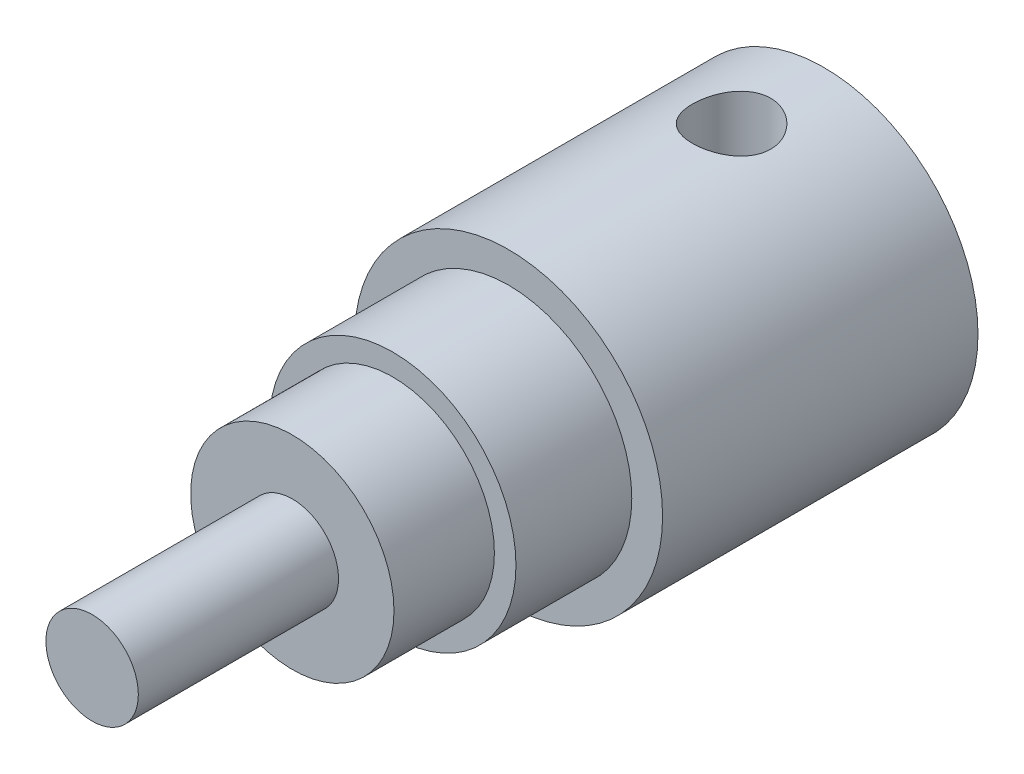
from build123d import *

# Parameters (mm, degrees)
ESQUISSE1_R                  = 25
BOSS_EXTRU_1_DEPTH           = 51.2
ESQUISSE2_R                  = 20
BOSS_EXTRU_2_DEPTH           = 18.8
ESQUISSE3_R                  = 16.5
BOSS_EXTRU_3_DEPTH           = 16.7
ESQUISSE4_R                  = 27.5
BOSS_EXTRU_4_DEPTH           = 47.1
CHANFREIN1_SIZE              = 10
CHANFREIN1_SIZE2             = 17.320508076
ESQUISSE12_R                 = 6.35
ENL_V_MAT_EXTRU_1_DEPTH      = 28.5
ENL_V_MAT_EXTRU_1_DEPTH_BACK = 28.5
ESQUISSE13_R                 = 47.258439022
ENL_V_MAT_EXTRU_2_DEPTH      = 15
ESQUISSE14_R                 = 39.934727028
ESQUISSE14_R_2               = 7.5
ENL_V_MAT_EXTRU_4_DEPTH      = 32.5


with BuildPart() as part:
    # Esquisse1 → Boss.-Extru.1 (new body)
    with BuildSketch(Plane.XY):
        Circle(ESQUISSE1_R)
    extrude(amount=BOSS_EXTRU_1_DEPTH)

    # Esquisse2 → Boss.-Extru.2 (add)
    with BuildSketch(Plane.XY.offset(51.2)):
        Circle(ESQUISSE2_R)
    extrude(amount=BOSS_EXTRU_2_DEPTH)

    # Esquisse3 → Boss.-Extru.3 (add)
    with BuildSketch(Plane.XY.offset(70)):
        Circle(ESQUISSE3_R)
    extrude(amount=BOSS_EXTRU_3_DEPTH)

    # Esquisse4 → Boss.-Extru.4 (add)
    with BuildSketch(Plane.XY.offset(86.7)):
        Circle(ESQUISSE4_R)
    extrude(amount=BOSS_EXTRU_4_DEPTH)

    # Chanfrein1
    chanfrein1_edges = [part.edges().sort_by_distance(p)[0] for p in [
        (-27.5, 0, 86.7),
    ]]
    chanfrein1_side = [part.faces().sort_by_distance(p)[0] for p in [
        (-26.722182541, 0, 86.7),
    ]]
    chamfer(chanfrein1_edges, length=CHANFREIN1_SIZE, length2=CHANFREIN1_SIZE2, reference=chanfrein1_side[0])

    # Esquisse12 → Enlèv. mat.-Extru.1 (cut, two sides)
    with BuildSketch(Plane(origin=(0, 0, 0), x_dir=(1, 0, 0), z_dir=(0, 1, 0))) as enl_v_mat_extru_1_sk:
        with Locations((0, -15)):
            Circle(ESQUISSE12_R)
    extrude(amount=ENL_V_MAT_EXTRU_1_DEPTH, mode=Mode.SUBTRACT)
    extrude(enl_v_mat_extru_1_sk.sketch, amount=-ENL_V_MAT_EXTRU_1_DEPTH_BACK, mode=Mode.SUBTRACT)

    # Esquisse13 → Enlèv. mat.-Extru.2 (cut)
    with BuildSketch(Plane.XY.offset(133.8)):
        with Locations((0.544033406, 0)):
            Circle(ESQUISSE13_R)
    extrude(amount=-ENL_V_MAT_EXTRU_2_DEPTH, mode=Mode.SUBTRACT)

    # Esquisse14 → Enlèv. mat.-Extru.4 (cut)
    with BuildSketch(Plane.XY.offset(118.8)):
        Circle(ESQUISSE14_R)
        Circle(ESQUISSE14_R_2, mode=Mode.SUBTRACT)
    extrude(amount=-ENL_V_MAT_EXTRU_4_DEPTH, mode=Mode.SUBTRACT)


solid = part.part
